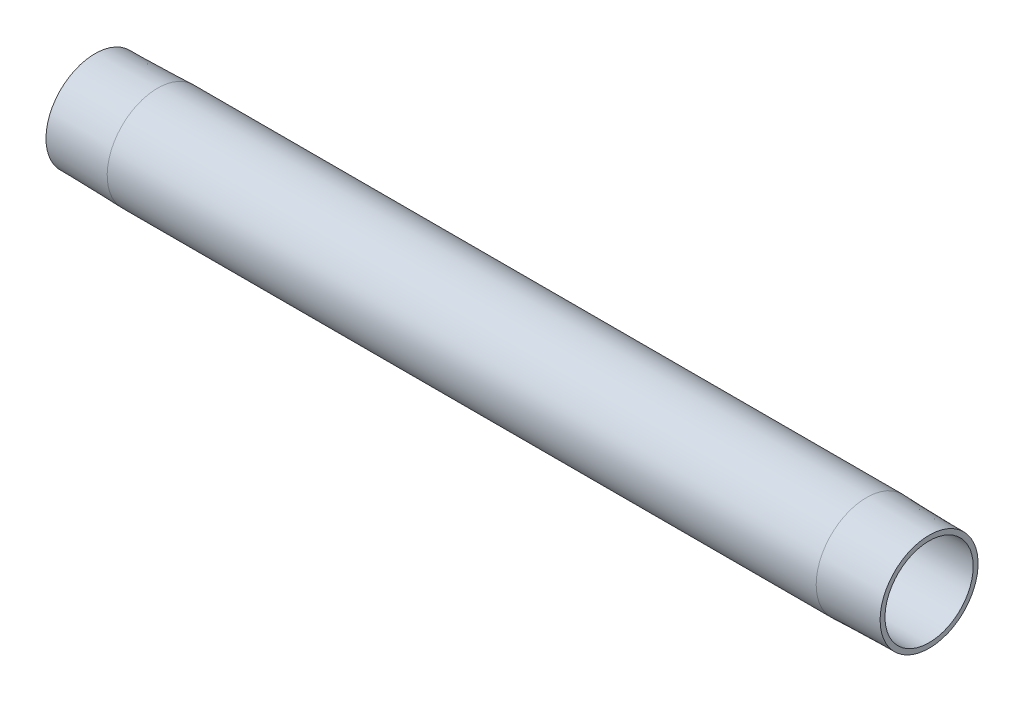
from build123d import *

# Parameters (mm, degrees)
SKETCH1_R           = 24.15
SKETCH1_R_2         = 21.15
BOSS_EXTRUDE1_DEPTH = 400


with BuildPart() as part:
    # Sketch1 → Boss-Extrude1 (new body)
    with BuildSketch(Plane(origin=(0, 0, 0), x_dir=(0, 0, -1), z_dir=(1, 0, 0))):
        Circle(SKETCH1_R)
        Circle(SKETCH1_R_2, mode=Mode.SUBTRACT)
    extrude(amount=-BOSS_EXTRUDE1_DEPTH)

    # Sketch2 → Cut-Revolve1 (revolve, cut)
    with BuildSketch(Plane.XY):
        Polygon((0, 24.15), (-30, 24.15), (0, 23.495397671), align=None)
    revolve(axis=Axis((0, 0, 0), (1, 0, 0)), mode=Mode.SUBTRACT)

    # Sketch3 → Cut-Revolve2 (revolve, cut)
    with BuildSketch(Plane.XY):
        Polygon((-400, 24.15), (-370, 24.15), (-400, 23.495397671), align=None)
    revolve(axis=Axis((-400, 0, 0), (1, 0, 0)), mode=Mode.SUBTRACT)


solid = part.part
